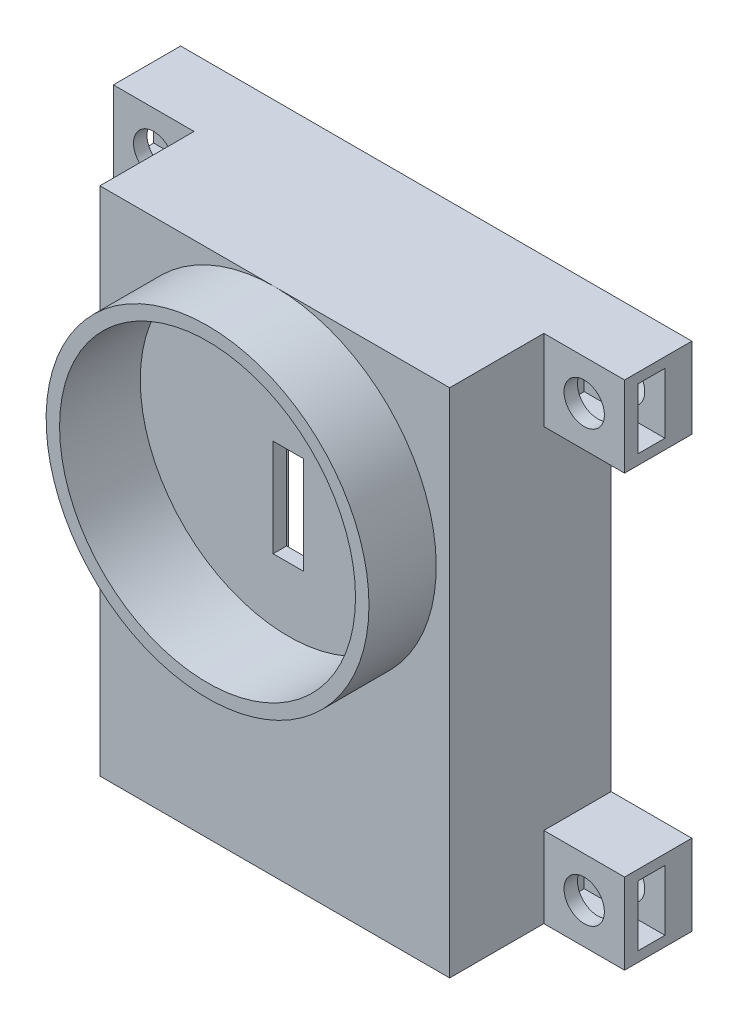
from build123d import *

# Parameters (mm, degrees)
SKETCH_1_W          = 26
SKETCH_1_H          = 38
EXTRUDE_1_DEPTH     = 12
SKETCH_2_W          = 22
SKETCH_2_H          = 34
CUT_EXTRUDE_1_DEPTH = 10
SKETCH_3_W          = 2.25
SKETCH_3_H          = 7.25
CUT_EXTRUDE_3_DEPTH = 12
SKETCH_4_W          = 6
SKETCH_4_H          = 6
EXTRUDE_2_DEPTH     = 5
SKETCH_5_R          = 1.5
CUT_EXTRUDE_4_DEPTH = 13
CUT_EXTRUDE_START   = 2
CUT_EXTRUDE_5_DEPTH = 1.6
SKETCH_7_R          = 12
SKETCH_7_R_2        = 11
EXTRUDE_3_DEPTH     = 5
SKETCH_9_R          = 11
CUT_EXTRUDE_7_DEPTH = 1
SKETCH_10_W         = 14.41096837
SKETCH_10_H         = 3
EXTRUDE_4_DEPTH     = 2
CUT_EXTRUDE_START_2 = 20
SKETCH_11_W         = 2
SKETCH_11_H         = 4.5
CUT_EXTRUDE_8_DEPTH = 7
CUT_EXTRUDE_START_3 = -20
SKETCH_13_W         = 2
SKETCH_13_H         = 4.5
CUT_EXTRUDE_9_DEPTH = 7


with BuildPart() as part:
    # ｽｹｯﾁ1 → ﾎﾞｽ - 押し出し1 (new body)
    with BuildSketch(Plane.XY):
        Rectangle(SKETCH_1_W, SKETCH_1_H)
    extrude(amount=EXTRUDE_1_DEPTH)

    # ｽｹｯﾁ2 → ｶｯﾄ - 押し出し1 (cut)
    with BuildSketch(Plane.XY):
        Rectangle(SKETCH_2_W, SKETCH_2_H)
    extrude(amount=CUT_EXTRUDE_1_DEPTH, mode=Mode.SUBTRACT)

    # ｽｹｯﾁ3 → ｶｯﾄ - 押し出し3 (cut)
    with BuildSketch(Plane.XY):
        with Locations((0, 4.375)):
            Rectangle(SKETCH_3_W, SKETCH_3_H)
    extrude(amount=CUT_EXTRUDE_3_DEPTH, mode=Mode.SUBTRACT)

    # ｽｹｯﾁ4 → ﾎﾞｽ - 押し出し2 (add)
    with BuildSketch(Plane.XY):
        with Locations((16, 16)):
            Rectangle(SKETCH_4_W, SKETCH_4_H)
        with Locations((16, -16)):
            Rectangle(SKETCH_4_W, SKETCH_4_H)
        with Locations((-16, -16)):
            Rectangle(SKETCH_4_W, SKETCH_4_H)
        with Locations((-16, 16)):
            Rectangle(SKETCH_4_W, SKETCH_4_H)
    extrude(amount=EXTRUDE_2_DEPTH)

    # ｽｹｯﾁ5 → ｶｯﾄ - 押し出し4 (cut, through all)
    with BuildSketch(Plane.XY):
        with Locations((-16, 16)):
            Circle(SKETCH_5_R)
        with Locations((-16, -16)):
            Circle(SKETCH_5_R)
        with Locations((16, -16)):
            Circle(SKETCH_5_R)
        with Locations((16, 16)):
            Circle(SKETCH_5_R)
    extrude(amount=CUT_EXTRUDE_4_DEPTH, mode=Mode.SUBTRACT)

    # ｽｹｯﾁ6 → ｶｯﾄ - 押し出し5 (cut)
    with BuildSketch(Plane.XY.offset(CUT_EXTRUDE_START)):
        Polygon((-17.184124892, 17.98272075), (-18.309148984, 15.965878137), (-17.125024092, 13.983157387), (-14.815875108, 14.01727925), (-13.690851016, 16.034121863), (-14.874975908, 18.016842613), align=None)
        Polygon((-17.154700538, -14), (-18.309401077, -16), (-17.154700538, -18), (-14.845299462, -18), (-13.690598923, -16), (-14.845299462, -14), align=None)
        Polygon((14.845299462, 18), (13.690598923, 16), (14.845299462, 14), (17.154700538, 14), (18.309401077, 16), (17.154700538, 18), align=None)
        Polygon((14.854466591, -13.994735294), (13.690623119, -15.98942868), (14.836156527, -17.994693386), (17.145533409, -18.005264706), (18.309376881, -16.01057132), (17.163843473, -14.005306614), align=None)
    extrude(amount=CUT_EXTRUDE_5_DEPTH, mode=Mode.SUBTRACT)

    # ｽｹｯﾁ7 → ﾎﾞｽ - 押し出し3 (add)
    with BuildSketch(Plane.XY.offset(12)):
        with Locations((0, 7)):
            Circle(SKETCH_7_R)
        with Locations((0, 7)):
            Circle(SKETCH_7_R_2, mode=Mode.SUBTRACT)
    extrude(amount=EXTRUDE_3_DEPTH)

    # ｽｹｯﾁ9 → ｶｯﾄ - 押し出し7 (cut)
    with BuildSketch(Plane.XY.offset(12)):
        with Locations((0, 7)):
            Circle(SKETCH_9_R)
    extrude(amount=-CUT_EXTRUDE_7_DEPTH, mode=Mode.SUBTRACT)

    # ｽｹｯﾁ10 → ﾎﾞｽ - 押し出し4 (add)
    with BuildSketch(Plane.XY.offset(10)):
        with Locations((0, -11.5)):
            Rectangle(SKETCH_10_W, SKETCH_10_H)
    extrude(amount=-EXTRUDE_4_DEPTH)

    # ｽｹｯﾁ11 → ｶｯﾄ - 押し出し8 (cut)
    with BuildSketch(Plane(origin=(0, 0, 0), x_dir=(0, 0, -1), z_dir=(1, 0, 0)).offset(CUT_EXTRUDE_START_2)):
        with Locations((-3, 16)):
            Rectangle(SKETCH_11_W, SKETCH_11_H)
        with Locations((-3, -16)):
            Rectangle(SKETCH_11_W, SKETCH_11_H)
    extrude(amount=-CUT_EXTRUDE_8_DEPTH, mode=Mode.SUBTRACT)

    # ｽｹｯﾁ13 → ｶｯﾄ - 押し出し9 (cut)
    with BuildSketch(Plane(origin=(0, 0, 0), x_dir=(0, 0, -1), z_dir=(1, 0, 0)).offset(CUT_EXTRUDE_START_3)):
        with Locations((-3, 16)):
            Rectangle(SKETCH_13_W, SKETCH_13_H)
        with Locations((-3, -16)):
            Rectangle(SKETCH_13_W, SKETCH_13_H)
    extrude(amount=CUT_EXTRUDE_9_DEPTH, mode=Mode.SUBTRACT)


solid = part.part
